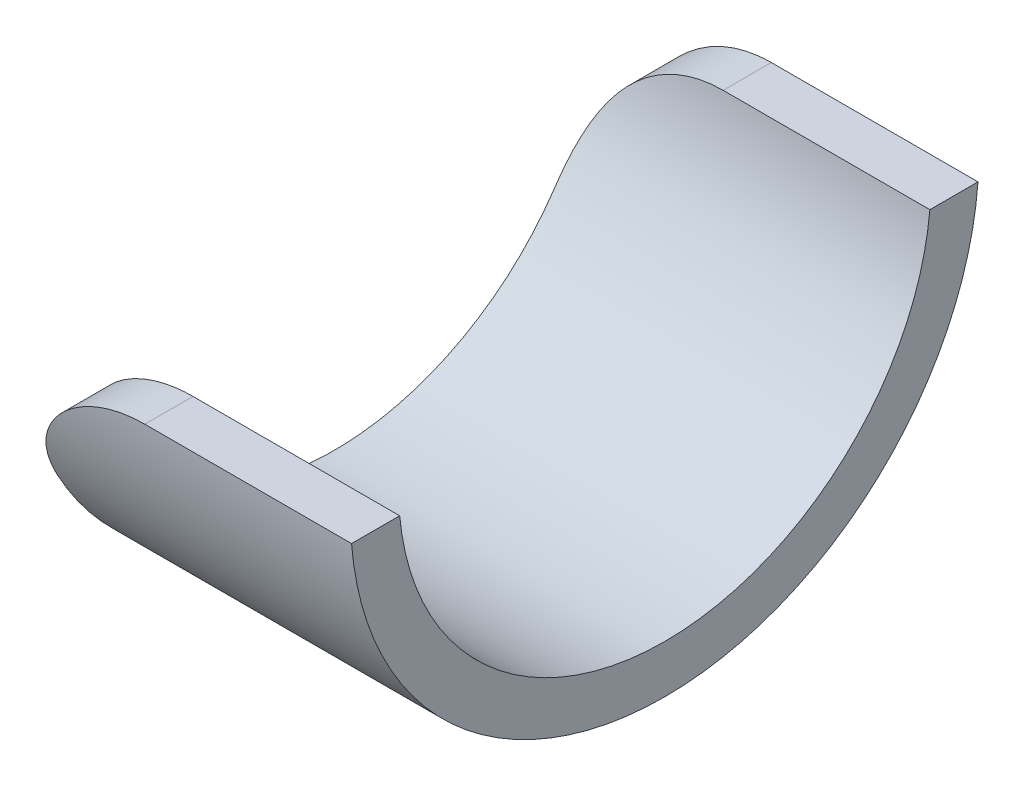
from build123d import *

# Parameters (mm, degrees)
BOSS_EXTRUDE1_DEPTH = 25.4
FILLET1_R           = 9.525


with BuildPart() as part:
    # Sketch1 → Boss-Extrude1 (new body)
    with BuildSketch(Plane(origin=(0, 0, 0), x_dir=(0, 0, -1), z_dir=(1, 0, 0))):
        with BuildLine():
            Line((-24.054685095, -1.905), (-20.358064348, -1.905))
            ThreePointArc((-20.358064348, -1.905), (0, -20.447), (20.358064348, -1.905))
            Line((20.358064348, -1.905), (24.054685095, -1.905))
            ThreePointArc((24.054685095, -1.905), (0, -24.13), (-24.054685095, -1.905))
        make_face()
    extrude(amount=BOSS_EXTRUDE1_DEPTH)

    # Fillet1
    fillet1_edges = [part.edges().sort_by_distance(p)[0] for p in [
        (0, -1.905, 22.206374721),
        (0, -1.905, -22.206374721),
    ]]
    fillet(fillet1_edges, radius=FILLET1_R)


solid = part.part
